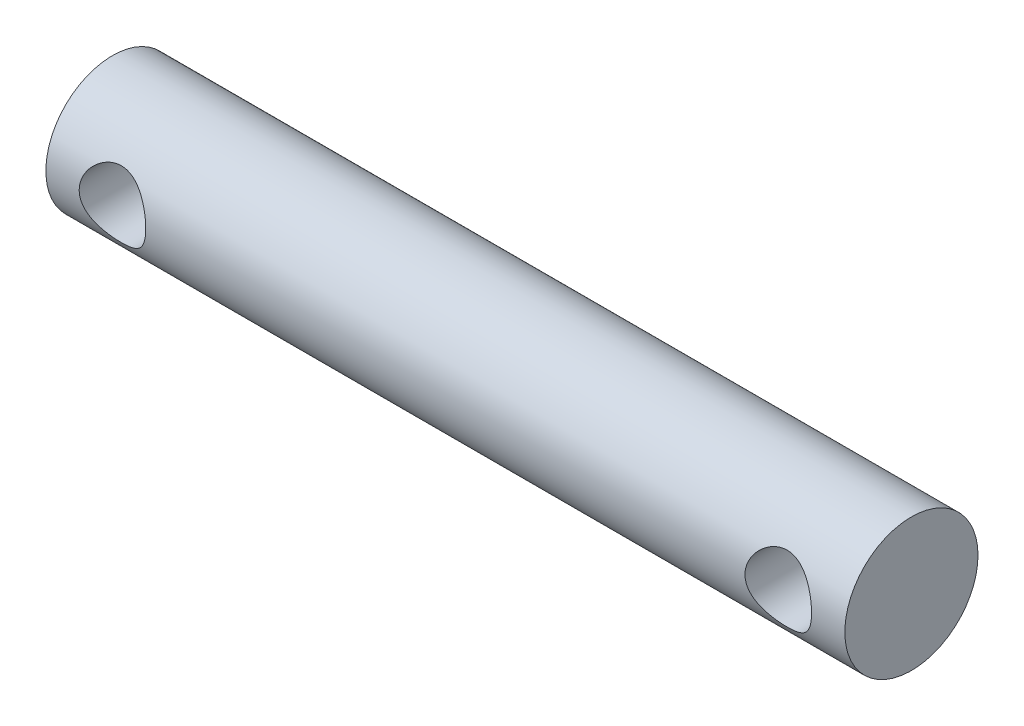
from build123d import *

# Parameters (mm, degrees)
SKETCH_1_R               = 3
EXTRUDE_1_DEPTH          = 36
SKETCH_2_R               = 1.5
CUT_EXTRUDE_1_DEPTH      = 4
CUT_EXTRUDE_1_DEPTH_BACK = 4


with BuildPart() as part:
    # 草圖1 → 填料-伸長1 (new body)
    with BuildSketch(Plane(origin=(0, 0, 0), x_dir=(0, 0, -1), z_dir=(1, 0, 0))):
        Circle(SKETCH_1_R)
    extrude(amount=EXTRUDE_1_DEPTH)

    # 草圖2 → 除料-伸長1 (cut, two sides)
    with BuildSketch(Plane.XY) as cut_extrude_1_sk:
        with Locations((3, 0)):
            Circle(SKETCH_2_R)
        with Locations((33, 0)):
            Circle(SKETCH_2_R)
    extrude(amount=CUT_EXTRUDE_1_DEPTH, mode=Mode.SUBTRACT)
    extrude(cut_extrude_1_sk.sketch, amount=-CUT_EXTRUDE_1_DEPTH_BACK, mode=Mode.SUBTRACT)


solid = part.part
